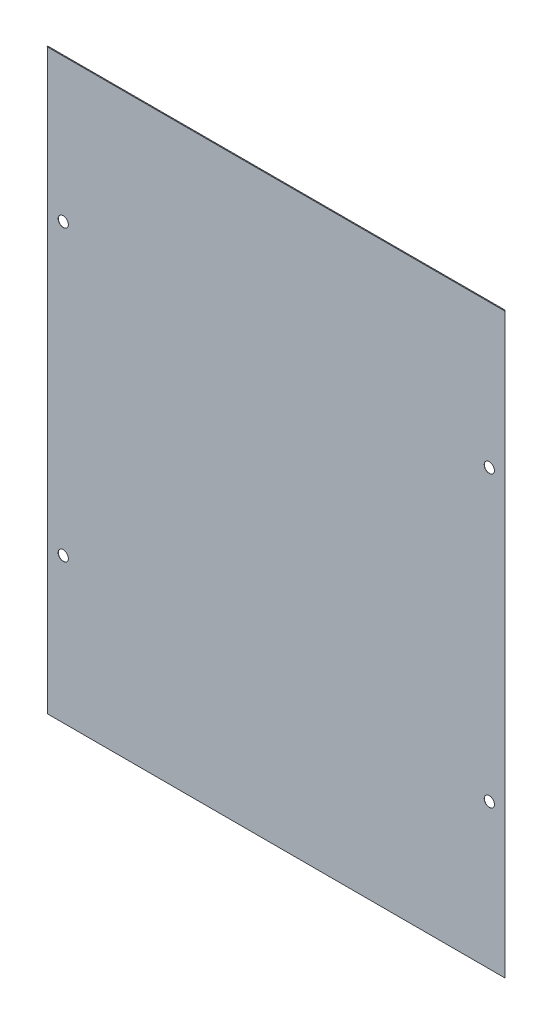
from build123d import *

# Parameters (mm, degrees)
SKETCH1_W          = 89.8724
SKETCH1_H          = 227.2896
SKETCH1_R          = 2
BODY_DEPTH         = 0.06858
SKETCH2_W          = 89.8724
SKETCH2_H          = 0.0686
TOP_OVERWRAP_DEPTH = 0.2896


with BuildPart() as part:
    # Sketch1 → Body (new body)
    with BuildSketch(Plane.XY):
        with Locations((-44.9362, 0)):
            Rectangle(SKETCH1_W, SKETCH1_H)
        with Locations((-83.71996894, -56.66618171)):
            Circle(SKETCH1_R, mode=Mode.SUBTRACT)
        with Locations((-83.71996894, 56.98616943)):
            Circle(SKETCH1_R, mode=Mode.SUBTRACT)
    body = extrude(amount=BODY_DEPTH)

    # Sketch2 → Top Overwrap (add)
    with BuildSketch(Plane(origin=(0, 227.3734, 0.06858), x_dir=(-1, 0, 0), z_dir=(0, 0, 1))):
        with Locations((44.9362, 113.7629)):
            Rectangle(SKETCH2_W, SKETCH2_H)
    top_overwrap = extrude(amount=TOP_OVERWRAP_DEPTH)

    # Mirror1: Body, Top Overwrap across plane
    add(body.mirror(Plane(origin=(0, 0, 0), x_dir=(0, 0, 1), z_dir=(1, 0, 0))))
    add(top_overwrap.mirror(Plane(origin=(0, 0, 0), x_dir=(0, 0, 1), z_dir=(1, 0, 0))))


solid = part.part
